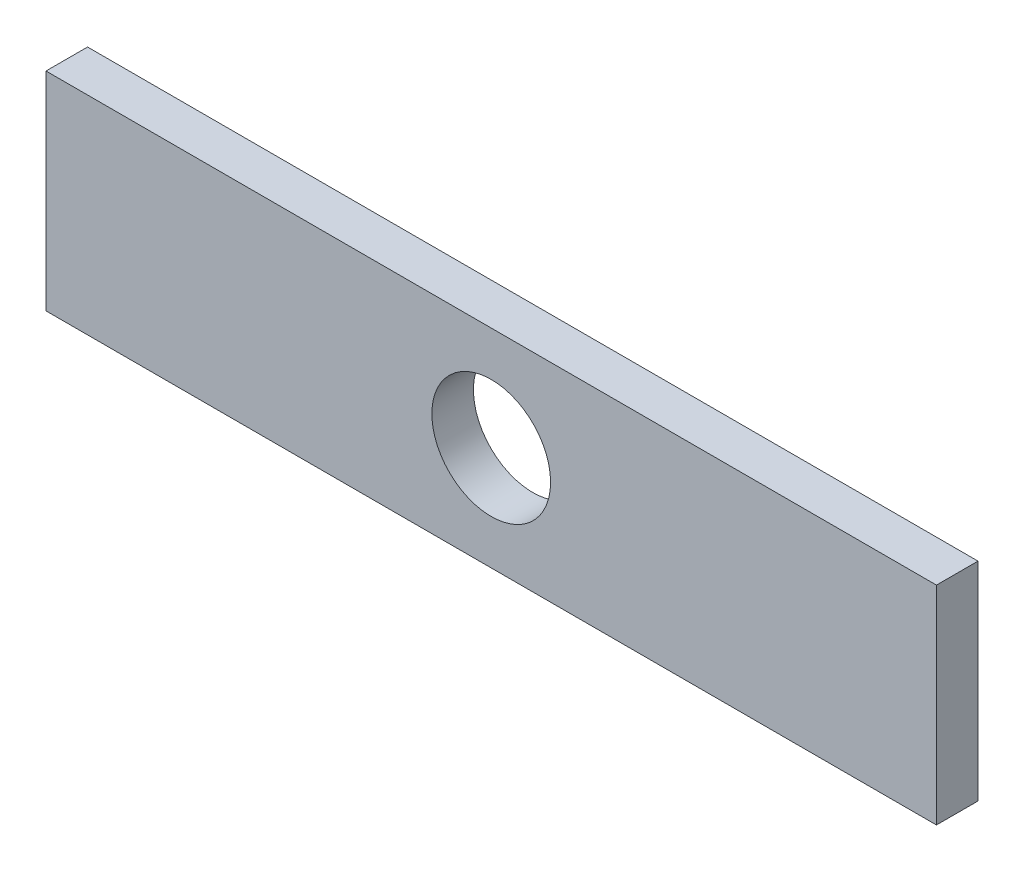
from build123d import *

# Parameters (mm, degrees)
SKETCH1_W           = 150
SKETCH1_H           = 35
SKETCH1_R           = 10
BOSS_EXTRUDE1_DEPTH = 7
SKETCH1_3_R         = 5
BOSS_EXTRUDE2_DEPTH = 10
SCALE1_SCALE        = 0.2
SCALE2_SCALE        = 2


with BuildPart() as part:
    # Sketch1 → Boss-Extrude1 (new body)
    with BuildSketch(Plane.XY):
        Rectangle(SKETCH1_W, SKETCH1_H)
        Circle(SKETCH1_R, mode=Mode.SUBTRACT)
    extrude(amount=BOSS_EXTRUDE1_DEPTH)

    # Sketch1_3 → Boss-Extrude2 (add)
    with BuildSketch(Plane.XY):
        with Locations((-60, 0)):
            Circle(SKETCH1_3_R)
        with Locations((-35, 0)):
            Circle(SKETCH1_3_R)
        with Locations((35, 0)):
            Circle(SKETCH1_3_R)
        with Locations((60, 0)):
            Circle(SKETCH1_3_R)
    extrude(amount=-BOSS_EXTRUDE2_DEPTH)


with BuildPart() as part_1:
    # Scale1: scaled about (0, 0, 2.791541997)
    add(part.part.scale(SCALE1_SCALE).moved(Location((0, 0, 2.233233598))))


with BuildPart() as part_2:
    # Scale2: scaled about (0, 0, 2.791541997)
    add(part_1.part.scale(SCALE2_SCALE).moved(Location((0, 0, -2.791541997))))


solid = part_2.part
